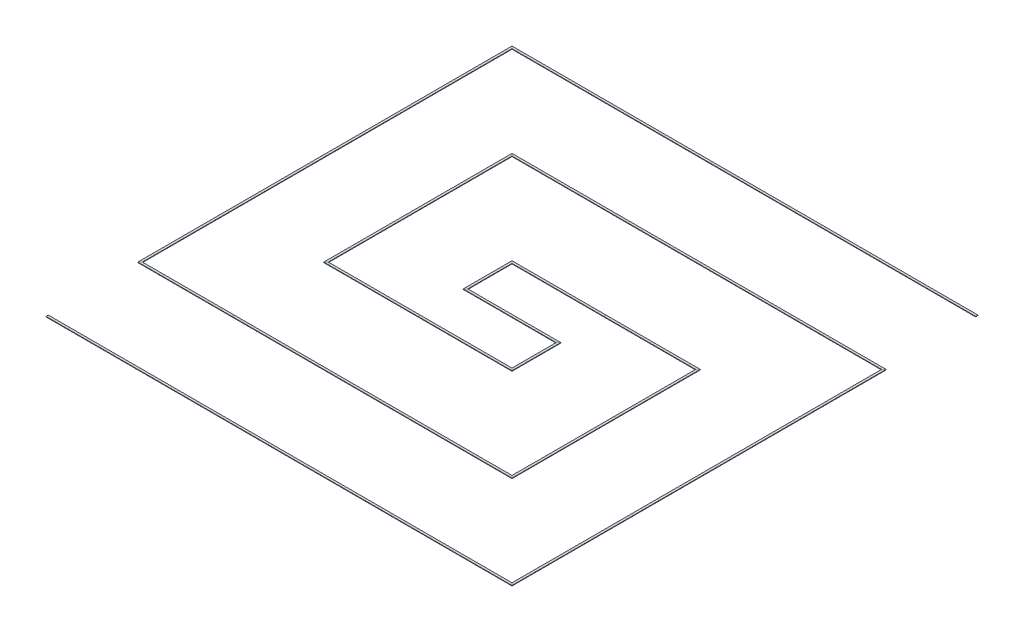
from build123d import *

# Parameters (mm, degrees)
SKETCH3_W = 0.025
SKETCH3_H = 0.005


with BuildPart() as part:
    # Sweep1: sweep along a path in Sketch2
    with BuildLine(Plane(origin=(0, 0, 0), x_dir=(1, 0, 0), z_dir=(0, 1, 0))) as sweep1_path:
        Line((-2.5, -2.5), (2.5, -2.5))
        Line((2.5, -2.5), (2.5, 1.5))
        Line((2.5, 1.5), (1.5, 1.5))
        Line((1.5, 1.5), (-1.5, 1.5))
        Line((-1.5, 1.5), (-1.5, -0.5))
        Line((-1.5, -0.5), (-0.5, -0.5))
        Line((-0.5, -0.5), (0.5, -0.5))
        Line((0.5, -0.5), (0.5, 0))
        Line((0.5, 0), (-0.5, 0))
        Line((-0.5, 0), (-0.5, 0.5))
        Line((-0.5, 0.5), (0.5, 0.5))
        Line((0.5, 0.5), (1.5, 0.5))
        Line((1.5, 0.5), (1.5, -1.5))
        Line((1.5, -1.5), (-1.5, -1.5))
        Line((-1.5, -1.5), (-2.5, -1.5))
        Line((-2.5, -1.5), (-2.5, 2.5))
        Line((-2.5, 2.5), (2.5, 2.5))
    # Sketch3 → Sweep1 (sweep)
    with BuildSketch(Plane(origin=(0, 0, 0), x_dir=(0, 0, -1), z_dir=(1, 0, 0))):
        Rectangle(SKETCH3_W, SKETCH3_H)
    sweep(path=sweep1_path.line, transition=Transition.RIGHT)


solid = part.part
